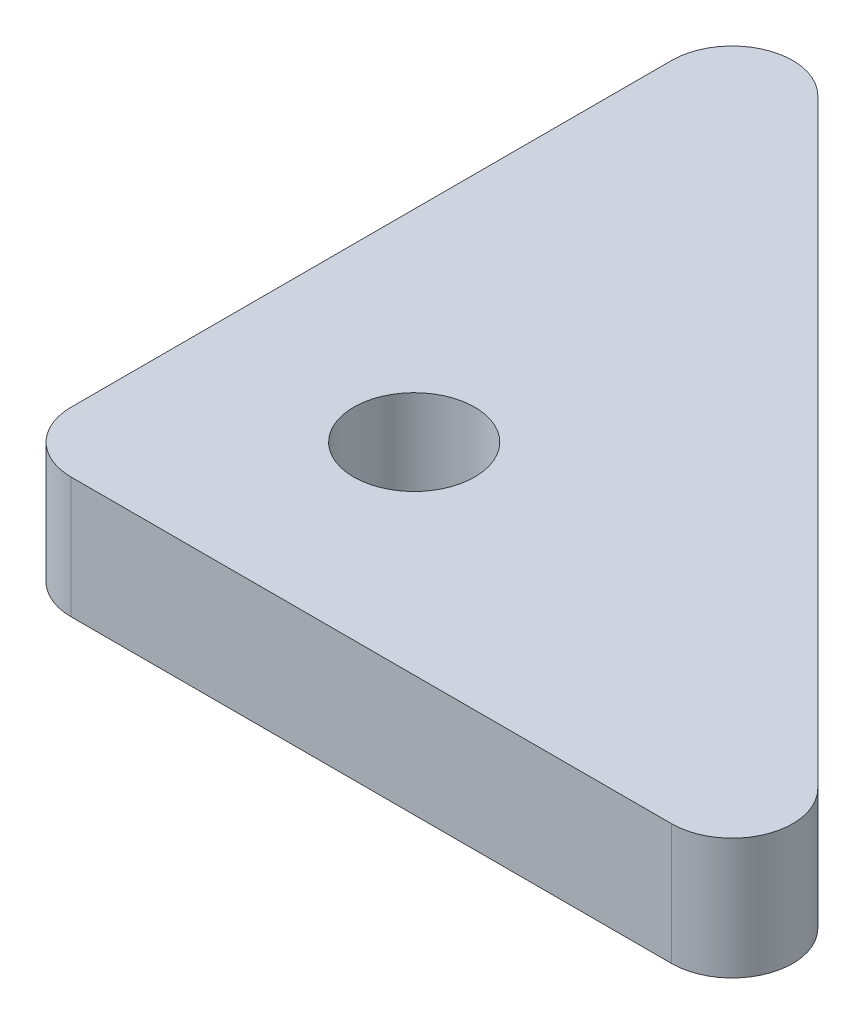
from build123d import *

# Parameters (mm, degrees)
SKETCH1_R           = 3
BOSS_EXTRUDE1_DEPTH = 6


with BuildPart() as part:
    # Sketch1 → Boss-Extrude1 (new body)
    with BuildSketch(Plane(origin=(0, 0, 0), x_dir=(1, 0, 0), z_dir=(0, 1, 0))):
        with BuildLine():
            Line((5.121320344, 34.878679656), (34.878679656, 5.121320344))
            ThreePointArc((34.878679656, 5.121320344), (35.52899791, 1.851949703), (32.757359313, 0))
            Line((32.757359313, 0), (3, 0))
            ThreePointArc((3, 0), (0.878679656, 0.878679656), (0, 3))
            Line((0, 3), (0, 32.757359313))
            ThreePointArc((0, 32.757359313), (1.851949703, 35.52899791), (5.121320344, 34.878679656))
        make_face()
        with Locations((10, 10)):
            Circle(SKETCH1_R, mode=Mode.SUBTRACT)
    extrude(amount=BOSS_EXTRUDE1_DEPTH)


solid = part.part
